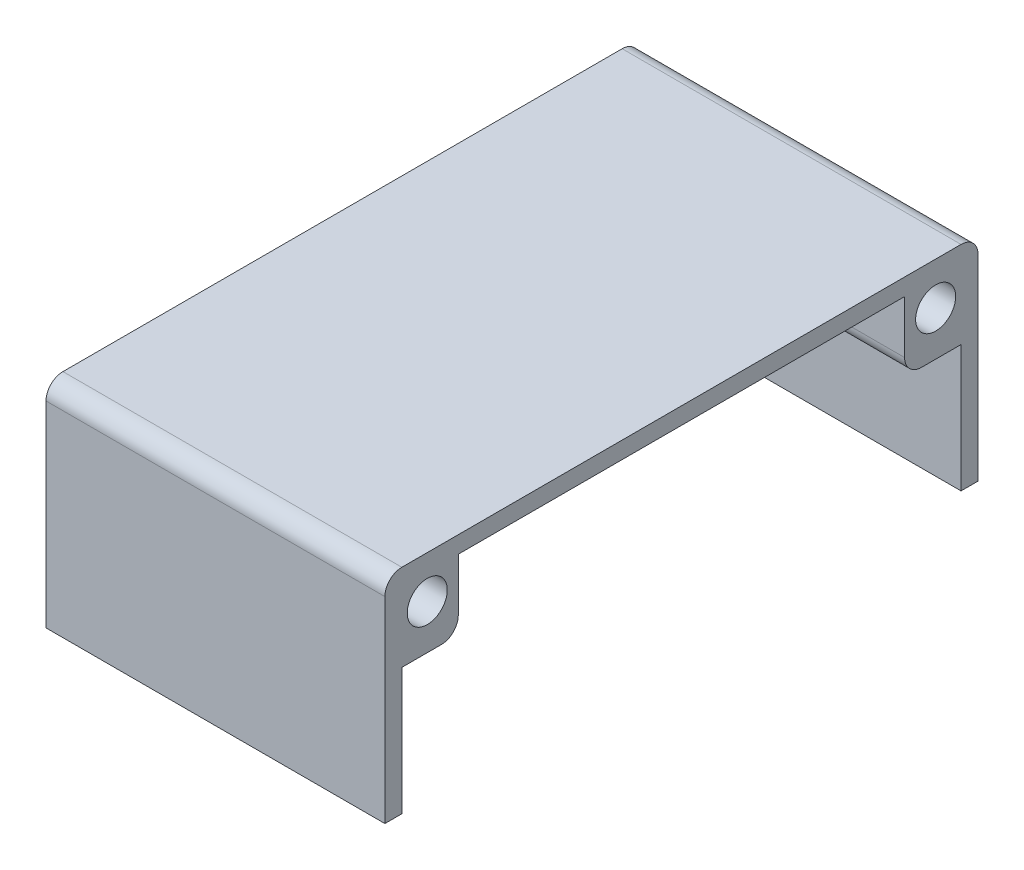
from build123d import *

# Parameters (mm, degrees)
SKETCH1_W           = 88.905
SKETCH1_H           = 32.004
BOSS_EXTRUDE1_DEPTH = 50.8
FILLET1_R           = 2.54
FILLET2_R           = 2.54
SKETCH13_W          = 83.825
SKETCH13_H          = 29.464
CUT_EXTRUDE1_DEPTH  = 90
SKETCH15_W          = 8.46
SKETCH15_H          = 10.46
SKETCH15_R          = 3
BOSS_EXTRUDE8_DEPTH = 50.8
SKETCH19_W          = 8.46
SKETCH19_H          = 10.46
SKETCH19_R          = 3
BOSS_EXTRUDE9_DEPTH = 50.8
FILLET3_R           = 2.54


with BuildPart() as part:
    # Sketch1 → Boss-Extrude1 (new body)
    with BuildSketch(Plane(origin=(0, 0, 0), x_dir=(0, 0, -1), z_dir=(1, 0, 0))):
        Rectangle(SKETCH1_W, SKETCH1_H)
    extrude(amount=BOSS_EXTRUDE1_DEPTH)

    # Fillet1
    fillet1_edges = [part.edges().sort_by_distance(p)[0] for p in [
        (25.4, 16.002, -44.4525),
    ]]
    fillet(fillet1_edges, radius=FILLET1_R)

    # Fillet2
    fillet2_edges = [part.edges().sort_by_distance(p)[0] for p in [
        (25.4, 16.002, 44.4525),
    ]]
    fillet(fillet2_edges, radius=FILLET2_R)

    # Sketch13 → Cut-Extrude1 (cut)
    with BuildSketch(Plane.ZY):
        with Locations((0, -1.27)):
            Rectangle(SKETCH13_W, SKETCH13_H)
    extrude(amount=-CUT_EXTRUDE1_DEPTH, mode=Mode.SUBTRACT)

    # Sketch15 → Boss-Extrude8 (add)
    with BuildSketch(Plane.ZY):
        with Locations((37.6825, 8.232)):
            Rectangle(SKETCH15_W, SKETCH15_H)
        with Locations((38.1025, 9.652)):
            Circle(SKETCH15_R, mode=Mode.SUBTRACT)
    extrude(amount=-BOSS_EXTRUDE8_DEPTH)

    # Sketch19 → Boss-Extrude9 (add)
    with BuildSketch(Plane.ZY):
        with Locations((-37.6825, 8.232)):
            Rectangle(SKETCH19_W, SKETCH19_H)
        with Locations((-38.1025, 9.652)):
            Circle(SKETCH19_R, mode=Mode.SUBTRACT)
    extrude(amount=-BOSS_EXTRUDE9_DEPTH)

    # Fillet3
    fillet3_edges = [part.edges().sort_by_distance(p)[0] for p in [
        (25.4, 3.002, 33.4525),
        (25.4, 3.002, -33.4525),
    ]]
    fillet(fillet3_edges, radius=FILLET3_R)


solid = part.part
